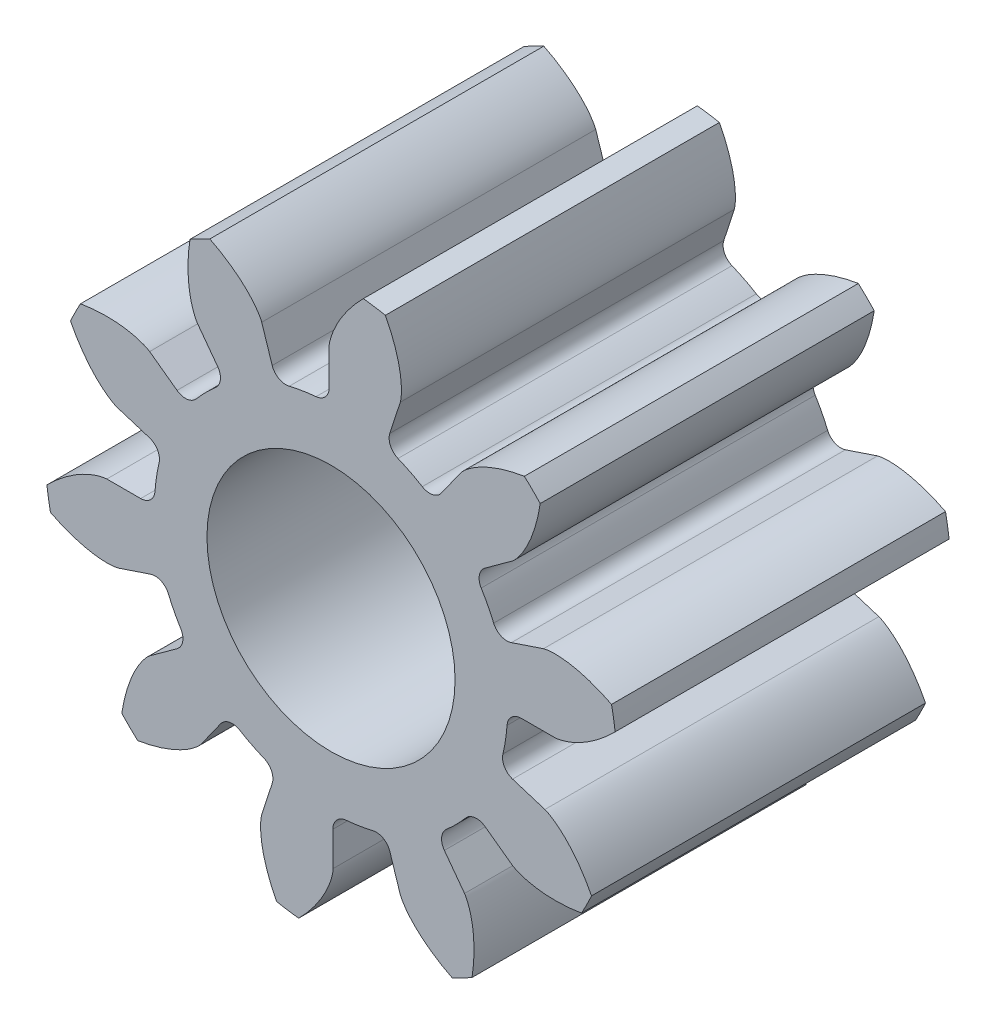
from build123d import *

# Parameters (mm, degrees)
BOSS_EXTRUDE3_DEPTH      = 7
FILLET1_R                = 0.3
CIRPATTERN8_COUNT        = 10
CIRPATTERN8_COPY_1_DEPTH = 7
CIRPATTERN8_COPY_2_DEPTH = 7
CIRPATTERN8_COPY_3_DEPTH = 7
CIRPATTERN8_COPY_4_DEPTH = 7
CIRPATTERN8_COPY_5_DEPTH = 7
CIRPATTERN8_COPY_6_DEPTH = 7
CIRPATTERN8_COPY_7_DEPTH = 7
CIRPATTERN8_COPY_8_DEPTH = 7
CIRPATTERN8_COPY_9_DEPTH = 7
FILLET1_OF_CIRPATTERN8_R = 0.3
SKETCH3_R                = 2.6
CUT_EXTRUDE2_DEPTH       = 8.0000001


with BuildPart() as part:
    # Sketch1 → Boss-Extrude3 (new body)
    with BuildSketch(Plane.XY):
        with BuildLine():
            Line((3.7, 0), (4.698463104, 0))
            add(Edge.make_bspline(
                [(4.698463104, 0), (4.701936693, 7.3507e-05), (4.711671667, 0.000507155), (4.730035453, 0.002224847), (4.759876783, 0.006298442), (4.79766874, 0.013349079), (4.846157716, 0.02458424), (4.902733795, 0.040529055), (4.964229103, 0.060864675), (5.030289125, 0.085989187), (5.095362708, 0.113680418), (5.159425932, 0.143715794), (5.222425493, 0.175792819), (5.297691656, 0.217156604), (5.386434991, 0.270222415), (5.487756287, 0.337177562), (5.599668365, 0.418847249), (5.710232197, 0.508010197), (5.812558898, 0.597496992), (5.886666635, 0.668145407), (5.93326076, 0.714427159), (5.954667219, 0.736164592)],
                knots=[0, 0, 0, 0, 0, 0.005376748, 0.015083688, 0.02853182, 0.046610139, 0.064854849, 0.092110525, 0.119476175, 0.146842495, 0.174208853, 0.201574955, 0.228941013, 0.256307345, 0.307035032, 0.361767351, 0.41649966, 0.471231936, 0.525964281, 0.573449371, 0.573449371, 0.573449371, 0.573449371, 0.573449371], degree=4))
            ThreePointArc((5.954667219, 0.736164592), (5.939189457, 0.852073114), (5.921455736, 0.967657983))
            Line((5.921455736, 0.967657983), (3.65156437, 0.596722423))
            ThreePointArc((3.65156437, 0.596722423), (3.687871213, 0.299342471), (3.7, 0))
        make_face()
        with BuildLine():
            ThreePointArc((-3.65156437, -0.596722423), (0.299342471, -3.687871213), (3.7, 0))
            ThreePointArc((3.7, 0), (3.687871213, 0.299342471), (3.65156437, 0.596722423))
            Line((3.65156437, 0.596722423), (-3.65156437, -0.596722423))
        make_face()
        with BuildLine():
            Line((-3.65156437, -0.596722423), (3.65156437, 0.596722423))
            ThreePointArc((3.65156437, 0.596722423), (-0.596722423, 3.65156437), (-3.65156437, -0.596722423))
        make_face()
    boss_extrude3 = extrude(amount=BOSS_EXTRUDE3_DEPTH)

    # Mirror2: Boss-Extrude3 across plane
    add(boss_extrude3.mirror(Plane(origin=(0, 0, 7), x_dir=(0, 0, 1), z_dir=(0.16127633, -0.986909289, 0))))

    # Fillet1
    fillet1_edges = [part.edges().sort_by_distance(p)[0] for p in [
        (3.7, 0, 3.5),
        (3.507525595, 1.177821804, 3.5),
    ]]
    fillet(fillet1_edges, radius=FILLET1_R)

    # CirPattern8: Boss-Extrude3 ×10 about axis
    cirpattern8_axis = Axis((0, 0, 7), (0, 0, -1))
    for i in range(1, CIRPATTERN8_COUNT):
        add(boss_extrude3.rotate(cirpattern8_axis, i * 360 / CIRPATTERN8_COUNT))

    # CirPattern8 copy 1 sketch → CirPattern8 copy 1 (add)
    with BuildSketch(Plane(origin=(0, 0, 0), x_dir=(0.954041649, -0.299674043, 0), z_dir=(0, 0, 1))):
        with BuildLine():
            Line((3.7, 0), (4.698463104, 0))
            add(Edge.make_bspline(
                [(4.698463104, 0), (4.701936693, -7.3507e-05), (4.711671667, -0.000507155), (4.730035453, -0.002224847), (4.759876783, -0.006298442), (4.79766874, -0.013349079), (4.846157716, -0.02458424), (4.902733795, -0.040529055), (4.964229103, -0.060864675), (5.030289125, -0.085989187), (5.095362708, -0.113680418), (5.159425932, -0.143715794), (5.222425493, -0.175792819), (5.297691656, -0.217156604), (5.386434991, -0.270222415), (5.487756287, -0.337177562), (5.599668365, -0.418847249), (5.710232197, -0.508010197), (5.812558898, -0.597496992), (5.886666635, -0.668145407), (5.93326076, -0.714427159), (5.954667219, -0.736164592)],
                knots=[0, 0, 0, 0, 0, 0.005376748, 0.015083688, 0.02853182, 0.046610139, 0.064854849, 0.092110525, 0.119476175, 0.146842495, 0.174208853, 0.201574955, 0.228941013, 0.256307345, 0.307035032, 0.361767351, 0.41649966, 0.471231936, 0.525964281, 0.573449371, 0.573449371, 0.573449371, 0.573449371, 0.573449371], degree=4))
            ThreePointArc((5.954667219, -0.736164592), (5.939189457, -0.852073114), (5.921455736, -0.967657983))
            Line((5.921455736, -0.967657983), (3.65156437, -0.596722423))
            ThreePointArc((3.65156437, -0.596722423), (3.687871213, -0.299342471), (3.7, 0))
        make_face()
        with BuildLine():
            ThreePointArc((-3.65156437, 0.596722423), (0.299342471, 3.687871213), (3.7, 0))
            ThreePointArc((3.7, 0), (3.687871213, -0.299342471), (3.65156437, -0.596722423))
            Line((3.65156437, -0.596722423), (-3.65156437, 0.596722423))
        make_face()
        with BuildLine():
            Line((-3.65156437, 0.596722423), (3.65156437, -0.596722423))
            ThreePointArc((3.65156437, -0.596722423), (-0.596722423, -3.65156437), (-3.65156437, 0.596722423))
        make_face()
    extrude(amount=CIRPATTERN8_COPY_1_DEPTH)

    # CirPattern8 copy 2 sketch → CirPattern8 copy 2 (add)
    with BuildSketch(Plane(origin=(0, 0, 0), x_dir=(0.595691924, -0.803213005, 0), z_dir=(0, 0, 1))):
        with BuildLine():
            Line((3.7, 0), (4.698463104, 0))
            add(Edge.make_bspline(
                [(4.698463104, 0), (4.701936693, -7.3507e-05), (4.711671667, -0.000507155), (4.730035453, -0.002224847), (4.759876783, -0.006298442), (4.79766874, -0.013349079), (4.846157716, -0.02458424), (4.902733795, -0.040529055), (4.964229103, -0.060864675), (5.030289125, -0.085989187), (5.095362708, -0.113680418), (5.159425932, -0.143715794), (5.222425493, -0.175792819), (5.297691656, -0.217156604), (5.386434991, -0.270222415), (5.487756287, -0.337177562), (5.599668365, -0.418847249), (5.710232197, -0.508010197), (5.812558898, -0.597496992), (5.886666635, -0.668145407), (5.93326076, -0.714427159), (5.954667219, -0.736164592)],
                knots=[0, 0, 0, 0, 0, 0.005376748, 0.015083688, 0.02853182, 0.046610139, 0.064854849, 0.092110525, 0.119476175, 0.146842495, 0.174208853, 0.201574955, 0.228941013, 0.256307345, 0.307035032, 0.361767351, 0.41649966, 0.471231936, 0.525964281, 0.573449371, 0.573449371, 0.573449371, 0.573449371, 0.573449371], degree=4))
            ThreePointArc((5.954667219, -0.736164592), (5.939189457, -0.852073114), (5.921455736, -0.967657983))
            Line((5.921455736, -0.967657983), (3.65156437, -0.596722423))
            ThreePointArc((3.65156437, -0.596722423), (3.687871213, -0.299342471), (3.7, 0))
        make_face()
        with BuildLine():
            ThreePointArc((-3.65156437, 0.596722423), (0.299342471, 3.687871213), (3.7, 0))
            ThreePointArc((3.7, 0), (3.687871213, -0.299342471), (3.65156437, -0.596722423))
            Line((3.65156437, -0.596722423), (-3.65156437, 0.596722423))
        make_face()
        with BuildLine():
            Line((-3.65156437, 0.596722423), (3.65156437, -0.596722423))
            ThreePointArc((3.65156437, -0.596722423), (-0.596722423, -3.65156437), (-3.65156437, 0.596722423))
        make_face()
    extrude(amount=CIRPATTERN8_COPY_2_DEPTH)

    # CirPattern8 copy 3 sketch → CirPattern8 copy 3 (add)
    with BuildSketch(Plane(origin=(0, 0, 0), x_dir=(0.009808131, -0.999951899, 0), z_dir=(0, 0, 1))):
        with BuildLine():
            Line((3.7, 0), (4.698463104, 0))
            add(Edge.make_bspline(
                [(4.698463104, 0), (4.701936693, -7.3507e-05), (4.711671667, -0.000507155), (4.730035453, -0.002224847), (4.759876783, -0.006298442), (4.79766874, -0.013349079), (4.846157716, -0.02458424), (4.902733795, -0.040529055), (4.964229103, -0.060864675), (5.030289125, -0.085989187), (5.095362708, -0.113680418), (5.159425932, -0.143715794), (5.222425493, -0.175792819), (5.297691656, -0.217156604), (5.386434991, -0.270222415), (5.487756287, -0.337177562), (5.599668365, -0.418847249), (5.710232197, -0.508010197), (5.812558898, -0.597496992), (5.886666635, -0.668145407), (5.93326076, -0.714427159), (5.954667219, -0.736164592)],
                knots=[0, 0, 0, 0, 0, 0.005376748, 0.015083688, 0.02853182, 0.046610139, 0.064854849, 0.092110525, 0.119476175, 0.146842495, 0.174208853, 0.201574955, 0.228941013, 0.256307345, 0.307035032, 0.361767351, 0.41649966, 0.471231936, 0.525964281, 0.573449371, 0.573449371, 0.573449371, 0.573449371, 0.573449371], degree=4))
            ThreePointArc((5.954667219, -0.736164592), (5.939189457, -0.852073114), (5.921455736, -0.967657983))
            Line((5.921455736, -0.967657983), (3.65156437, -0.596722423))
            ThreePointArc((3.65156437, -0.596722423), (3.687871213, -0.299342471), (3.7, 0))
        make_face()
        with BuildLine():
            ThreePointArc((-3.65156437, 0.596722423), (0.299342471, 3.687871213), (3.7, 0))
            ThreePointArc((3.7, 0), (3.687871213, -0.299342471), (3.65156437, -0.596722423))
            Line((3.65156437, -0.596722423), (-3.65156437, 0.596722423))
        make_face()
        with BuildLine():
            Line((-3.65156437, 0.596722423), (3.65156437, -0.596722423))
            ThreePointArc((3.65156437, -0.596722423), (-0.596722423, -3.65156437), (-3.65156437, 0.596722423))
        make_face()
    extrude(amount=CIRPATTERN8_COPY_3_DEPTH)

    # CirPattern8 copy 4 sketch → CirPattern8 copy 4 (add)
    with BuildSketch(Plane(origin=(0, 0, 0), x_dir=(-0.579822035, -0.814743155, 0), z_dir=(0, 0, 1))):
        with BuildLine():
            Line((3.7, 0), (4.698463104, 0))
            add(Edge.make_bspline(
                [(4.698463104, 0), (4.701936693, -7.3507e-05), (4.711671667, -0.000507155), (4.730035453, -0.002224847), (4.759876783, -0.006298442), (4.79766874, -0.013349079), (4.846157716, -0.02458424), (4.902733795, -0.040529055), (4.964229103, -0.060864675), (5.030289125, -0.085989187), (5.095362708, -0.113680418), (5.159425932, -0.143715794), (5.222425493, -0.175792819), (5.297691656, -0.217156604), (5.386434991, -0.270222415), (5.487756287, -0.337177562), (5.599668365, -0.418847249), (5.710232197, -0.508010197), (5.812558898, -0.597496992), (5.886666635, -0.668145407), (5.93326076, -0.714427159), (5.954667219, -0.736164592)],
                knots=[0, 0, 0, 0, 0, 0.005376748, 0.015083688, 0.02853182, 0.046610139, 0.064854849, 0.092110525, 0.119476175, 0.146842495, 0.174208853, 0.201574955, 0.228941013, 0.256307345, 0.307035032, 0.361767351, 0.41649966, 0.471231936, 0.525964281, 0.573449371, 0.573449371, 0.573449371, 0.573449371, 0.573449371], degree=4))
            ThreePointArc((5.954667219, -0.736164592), (5.939189457, -0.852073114), (5.921455736, -0.967657983))
            Line((5.921455736, -0.967657983), (3.65156437, -0.596722423))
            ThreePointArc((3.65156437, -0.596722423), (3.687871213, -0.299342471), (3.7, 0))
        make_face()
        with BuildLine():
            ThreePointArc((-3.65156437, 0.596722423), (0.299342471, 3.687871213), (3.7, 0))
            ThreePointArc((3.7, 0), (3.687871213, -0.299342471), (3.65156437, -0.596722423))
            Line((3.65156437, -0.596722423), (-3.65156437, 0.596722423))
        make_face()
        with BuildLine():
            Line((-3.65156437, 0.596722423), (3.65156437, -0.596722423))
            ThreePointArc((3.65156437, -0.596722423), (-0.596722423, -3.65156437), (-3.65156437, 0.596722423))
        make_face()
    extrude(amount=CIRPATTERN8_COPY_4_DEPTH)

    # CirPattern8 copy 5 sketch → CirPattern8 copy 5 (add)
    with BuildSketch(Plane(origin=(0, 0, 0), x_dir=(-0.94797989, -0.318330217, 0), z_dir=(0, 0, 1))):
        with BuildLine():
            Line((3.7, 0), (4.698463104, 0))
            add(Edge.make_bspline(
                [(4.698463104, 0), (4.701936693, -7.3507e-05), (4.711671667, -0.000507155), (4.730035453, -0.002224847), (4.759876783, -0.006298442), (4.79766874, -0.013349079), (4.846157716, -0.02458424), (4.902733795, -0.040529055), (4.964229103, -0.060864675), (5.030289125, -0.085989187), (5.095362708, -0.113680418), (5.159425932, -0.143715794), (5.222425493, -0.175792819), (5.297691656, -0.217156604), (5.386434991, -0.270222415), (5.487756287, -0.337177562), (5.599668365, -0.418847249), (5.710232197, -0.508010197), (5.812558898, -0.597496992), (5.886666635, -0.668145407), (5.93326076, -0.714427159), (5.954667219, -0.736164592)],
                knots=[0, 0, 0, 0, 0, 0.005376748, 0.015083688, 0.02853182, 0.046610139, 0.064854849, 0.092110525, 0.119476175, 0.146842495, 0.174208853, 0.201574955, 0.228941013, 0.256307345, 0.307035032, 0.361767351, 0.41649966, 0.471231936, 0.525964281, 0.573449371, 0.573449371, 0.573449371, 0.573449371, 0.573449371], degree=4))
            ThreePointArc((5.954667219, -0.736164592), (5.939189457, -0.852073114), (5.921455736, -0.967657983))
            Line((5.921455736, -0.967657983), (3.65156437, -0.596722423))
            ThreePointArc((3.65156437, -0.596722423), (3.687871213, -0.299342471), (3.7, 0))
        make_face()
        with BuildLine():
            ThreePointArc((-3.65156437, 0.596722423), (0.299342471, 3.687871213), (3.7, 0))
            ThreePointArc((3.7, 0), (3.687871213, -0.299342471), (3.65156437, -0.596722423))
            Line((3.65156437, -0.596722423), (-3.65156437, 0.596722423))
        make_face()
        with BuildLine():
            Line((-3.65156437, 0.596722423), (3.65156437, -0.596722423))
            ThreePointArc((3.65156437, -0.596722423), (-0.596722423, -3.65156437), (-3.65156437, 0.596722423))
        make_face()
    extrude(amount=CIRPATTERN8_COPY_5_DEPTH)

    # CirPattern8 copy 6 sketch → CirPattern8 copy 6 (add)
    with BuildSketch(Plane(origin=(0, 0, 0), x_dir=(-0.954041649, 0.299674043, 0), z_dir=(0, 0, 1))):
        with BuildLine():
            Line((3.7, 0), (4.698463104, 0))
            add(Edge.make_bspline(
                [(4.698463104, 0), (4.701936693, -7.3507e-05), (4.711671667, -0.000507155), (4.730035453, -0.002224847), (4.759876783, -0.006298442), (4.79766874, -0.013349079), (4.846157716, -0.02458424), (4.902733795, -0.040529055), (4.964229103, -0.060864675), (5.030289125, -0.085989187), (5.095362708, -0.113680418), (5.159425932, -0.143715794), (5.222425493, -0.175792819), (5.297691656, -0.217156604), (5.386434991, -0.270222415), (5.487756287, -0.337177562), (5.599668365, -0.418847249), (5.710232197, -0.508010197), (5.812558898, -0.597496992), (5.886666635, -0.668145407), (5.93326076, -0.714427159), (5.954667219, -0.736164592)],
                knots=[0, 0, 0, 0, 0, 0.005376748, 0.015083688, 0.02853182, 0.046610139, 0.064854849, 0.092110525, 0.119476175, 0.146842495, 0.174208853, 0.201574955, 0.228941013, 0.256307345, 0.307035032, 0.361767351, 0.41649966, 0.471231936, 0.525964281, 0.573449371, 0.573449371, 0.573449371, 0.573449371, 0.573449371], degree=4))
            ThreePointArc((5.954667219, -0.736164592), (5.939189457, -0.852073114), (5.921455736, -0.967657983))
            Line((5.921455736, -0.967657983), (3.65156437, -0.596722423))
            ThreePointArc((3.65156437, -0.596722423), (3.687871213, -0.299342471), (3.7, 0))
        make_face()
        with BuildLine():
            ThreePointArc((-3.65156437, 0.596722423), (0.299342471, 3.687871213), (3.7, 0))
            ThreePointArc((3.7, 0), (3.687871213, -0.299342471), (3.65156437, -0.596722423))
            Line((3.65156437, -0.596722423), (-3.65156437, 0.596722423))
        make_face()
        with BuildLine():
            Line((-3.65156437, 0.596722423), (3.65156437, -0.596722423))
            ThreePointArc((3.65156437, -0.596722423), (-0.596722423, -3.65156437), (-3.65156437, 0.596722423))
        make_face()
    extrude(amount=CIRPATTERN8_COPY_6_DEPTH)

    # CirPattern8 copy 7 sketch → CirPattern8 copy 7 (add)
    with BuildSketch(Plane(origin=(0, 0, 0), x_dir=(-0.595691924, 0.803213005, 0), z_dir=(0, 0, 1))):
        with BuildLine():
            Line((3.7, 0), (4.698463104, 0))
            add(Edge.make_bspline(
                [(4.698463104, 0), (4.701936693, -7.3507e-05), (4.711671667, -0.000507155), (4.730035453, -0.002224847), (4.759876783, -0.006298442), (4.79766874, -0.013349079), (4.846157716, -0.02458424), (4.902733795, -0.040529055), (4.964229103, -0.060864675), (5.030289125, -0.085989187), (5.095362708, -0.113680418), (5.159425932, -0.143715794), (5.222425493, -0.175792819), (5.297691656, -0.217156604), (5.386434991, -0.270222415), (5.487756287, -0.337177562), (5.599668365, -0.418847249), (5.710232197, -0.508010197), (5.812558898, -0.597496992), (5.886666635, -0.668145407), (5.93326076, -0.714427159), (5.954667219, -0.736164592)],
                knots=[0, 0, 0, 0, 0, 0.005376748, 0.015083688, 0.02853182, 0.046610139, 0.064854849, 0.092110525, 0.119476175, 0.146842495, 0.174208853, 0.201574955, 0.228941013, 0.256307345, 0.307035032, 0.361767351, 0.41649966, 0.471231936, 0.525964281, 0.573449371, 0.573449371, 0.573449371, 0.573449371, 0.573449371], degree=4))
            ThreePointArc((5.954667219, -0.736164592), (5.939189457, -0.852073114), (5.921455736, -0.967657983))
            Line((5.921455736, -0.967657983), (3.65156437, -0.596722423))
            ThreePointArc((3.65156437, -0.596722423), (3.687871213, -0.299342471), (3.7, 0))
        make_face()
        with BuildLine():
            ThreePointArc((-3.65156437, 0.596722423), (0.299342471, 3.687871213), (3.7, 0))
            ThreePointArc((3.7, 0), (3.687871213, -0.299342471), (3.65156437, -0.596722423))
            Line((3.65156437, -0.596722423), (-3.65156437, 0.596722423))
        make_face()
        with BuildLine():
            Line((-3.65156437, 0.596722423), (3.65156437, -0.596722423))
            ThreePointArc((3.65156437, -0.596722423), (-0.596722423, -3.65156437), (-3.65156437, 0.596722423))
        make_face()
    extrude(amount=CIRPATTERN8_COPY_7_DEPTH)

    # CirPattern8 copy 8 sketch → CirPattern8 copy 8 (add)
    with BuildSketch(Plane(origin=(0, 0, 0), x_dir=(-0.009808131, 0.999951899, 0), z_dir=(0, 0, 1))):
        with BuildLine():
            Line((3.7, 0), (4.698463104, 0))
            add(Edge.make_bspline(
                [(4.698463104, 0), (4.701936693, -7.3507e-05), (4.711671667, -0.000507155), (4.730035453, -0.002224847), (4.759876783, -0.006298442), (4.79766874, -0.013349079), (4.846157716, -0.02458424), (4.902733795, -0.040529055), (4.964229103, -0.060864675), (5.030289125, -0.085989187), (5.095362708, -0.113680418), (5.159425932, -0.143715794), (5.222425493, -0.175792819), (5.297691656, -0.217156604), (5.386434991, -0.270222415), (5.487756287, -0.337177562), (5.599668365, -0.418847249), (5.710232197, -0.508010197), (5.812558898, -0.597496992), (5.886666635, -0.668145407), (5.93326076, -0.714427159), (5.954667219, -0.736164592)],
                knots=[0, 0, 0, 0, 0, 0.005376748, 0.015083688, 0.02853182, 0.046610139, 0.064854849, 0.092110525, 0.119476175, 0.146842495, 0.174208853, 0.201574955, 0.228941013, 0.256307345, 0.307035032, 0.361767351, 0.41649966, 0.471231936, 0.525964281, 0.573449371, 0.573449371, 0.573449371, 0.573449371, 0.573449371], degree=4))
            ThreePointArc((5.954667219, -0.736164592), (5.939189457, -0.852073114), (5.921455736, -0.967657983))
            Line((5.921455736, -0.967657983), (3.65156437, -0.596722423))
            ThreePointArc((3.65156437, -0.596722423), (3.687871213, -0.299342471), (3.7, 0))
        make_face()
        with BuildLine():
            ThreePointArc((-3.65156437, 0.596722423), (0.299342471, 3.687871213), (3.7, 0))
            ThreePointArc((3.7, 0), (3.687871213, -0.299342471), (3.65156437, -0.596722423))
            Line((3.65156437, -0.596722423), (-3.65156437, 0.596722423))
        make_face()
        with BuildLine():
            Line((-3.65156437, 0.596722423), (3.65156437, -0.596722423))
            ThreePointArc((3.65156437, -0.596722423), (-0.596722423, -3.65156437), (-3.65156437, 0.596722423))
        make_face()
    extrude(amount=CIRPATTERN8_COPY_8_DEPTH)

    # CirPattern8 copy 9 sketch → CirPattern8 copy 9 (add)
    with BuildSketch(Plane(origin=(0, 0, 0), x_dir=(0.579822035, 0.814743155, 0), z_dir=(0, 0, 1))):
        with BuildLine():
            Line((3.7, 0), (4.698463104, 0))
            add(Edge.make_bspline(
                [(4.698463104, 0), (4.701936693, -7.3507e-05), (4.711671667, -0.000507155), (4.730035453, -0.002224847), (4.759876783, -0.006298442), (4.79766874, -0.013349079), (4.846157716, -0.02458424), (4.902733795, -0.040529055), (4.964229103, -0.060864675), (5.030289125, -0.085989187), (5.095362708, -0.113680418), (5.159425932, -0.143715794), (5.222425493, -0.175792819), (5.297691656, -0.217156604), (5.386434991, -0.270222415), (5.487756287, -0.337177562), (5.599668365, -0.418847249), (5.710232197, -0.508010197), (5.812558898, -0.597496992), (5.886666635, -0.668145407), (5.93326076, -0.714427159), (5.954667219, -0.736164592)],
                knots=[0, 0, 0, 0, 0, 0.005376748, 0.015083688, 0.02853182, 0.046610139, 0.064854849, 0.092110525, 0.119476175, 0.146842495, 0.174208853, 0.201574955, 0.228941013, 0.256307345, 0.307035032, 0.361767351, 0.41649966, 0.471231936, 0.525964281, 0.573449371, 0.573449371, 0.573449371, 0.573449371, 0.573449371], degree=4))
            ThreePointArc((5.954667219, -0.736164592), (5.939189457, -0.852073114), (5.921455736, -0.967657983))
            Line((5.921455736, -0.967657983), (3.65156437, -0.596722423))
            ThreePointArc((3.65156437, -0.596722423), (3.687871213, -0.299342471), (3.7, 0))
        make_face()
        with BuildLine():
            ThreePointArc((-3.65156437, 0.596722423), (0.299342471, 3.687871213), (3.7, 0))
            ThreePointArc((3.7, 0), (3.687871213, -0.299342471), (3.65156437, -0.596722423))
            Line((3.65156437, -0.596722423), (-3.65156437, 0.596722423))
        make_face()
        with BuildLine():
            Line((-3.65156437, 0.596722423), (3.65156437, -0.596722423))
            ThreePointArc((3.65156437, -0.596722423), (-0.596722423, -3.65156437), (-3.65156437, 0.596722423))
        make_face()
    extrude(amount=CIRPATTERN8_COPY_9_DEPTH)

    # Fillet1 of CirPattern8
    fillet1_of_cirpattern8_edges = [part.edges().sort_by_distance(p)[0] for p in [
        (2.993362879, -2.174805433, 3.5),
        (3.529954101, -1.108793961, 3.5),
        (1.143362879, -3.51890911, 3.5),
        (2.204060119, -2.971888119, 3.5),
        (-1.143362879, -3.51890911, 3.5),
        (0.036290085, -3.699822027, 3.5),
        (-2.993362879, -2.174805433, 3.5),
        (-2.145341528, -3.014549673, 3.5),
        (-3.7, 0, 3.5),
        (-3.507525595, -1.177821804, 3.5),
        (-2.993362879, 2.174805433, 3.5),
        (-3.529954101, 1.108793961, 3.5),
        (-1.143362879, 3.51890911, 3.5),
        (-2.204060119, 2.971888119, 3.5),
        (1.143362879, 3.51890911, 3.5),
        (-0.036290085, 3.699822027, 3.5),
        (2.993362879, 2.174805433, 3.5),
        (2.145341528, 3.014549673, 3.5),
    ]]
    fillet(fillet1_of_cirpattern8_edges, radius=FILLET1_OF_CIRPATTERN8_R)

    # Sketch3 → Cut-Extrude2 (cut, through all)
    with BuildSketch(Plane.XY.offset(7)):
        Circle(SKETCH3_R)
    extrude(amount=-CUT_EXTRUDE2_DEPTH, mode=Mode.SUBTRACT)


solid = part.part
